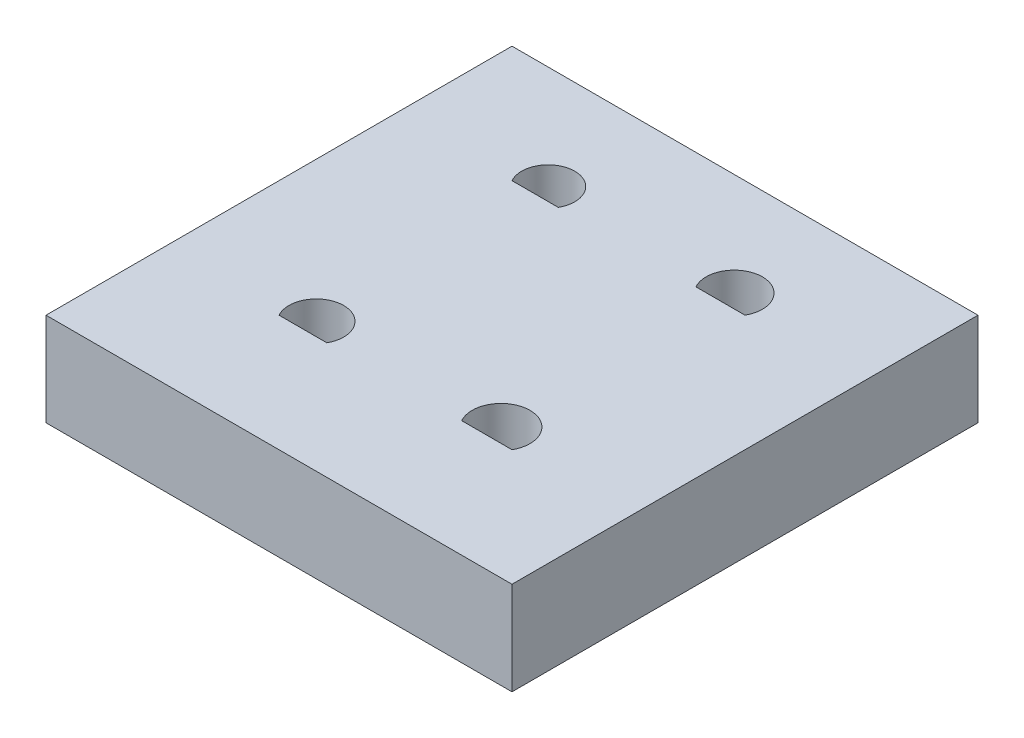
from build123d import *

# Parameters (mm, degrees)
SKETCH2_W           = 25.4
SKETCH2_H           = 25.4
BOSS_EXTRUDE1_DEPTH = 5.08
CUT_EXTRUDE1_DEPTH  = 5.08


with BuildPart() as part:
    # Sketch2 → Boss-Extrude1 (new body)
    with BuildSketch(Plane(origin=(0, 0, 0), x_dir=(1, 0, 0), z_dir=(0, 1, 0))):
        with Locations((12.7, 12.7)):
            Rectangle(SKETCH2_W, SKETCH2_H)
    extrude(amount=BOSS_EXTRUDE1_DEPTH)

    # Sketch3 → Cut-Extrude1 (cut)
    with BuildSketch(Plane(origin=(0, 5.08, 5.08), x_dir=(1, 0, 0), z_dir=(0, 1, 0))):
        with BuildLine():
            Line((6.35, 11.43), (8.957059761, 11.43))
            ThreePointArc((8.957059761, 11.43), (7.653529881, 13.6525), (6.35, 11.43))
        make_face()
        with BuildLine():
            Line((16.307858538, 11.43), (19.05, 11.43))
            ThreePointArc((19.05, 11.43), (17.678929269, 13.7795), (16.307858538, 11.43))
        make_face()
        with BuildLine():
            Line((6.35, 24.13), (8.872157331, 24.13))
            ThreePointArc((8.872157331, 24.13), (7.611078665, 26.289), (6.35, 24.13))
        make_face()
        with BuildLine():
            Line((16.375390855, 24.13), (19.05, 24.13))
            ThreePointArc((19.05, 24.13), (17.712695427, 26.416), (16.375390855, 24.13))
        make_face()
    extrude(amount=-CUT_EXTRUDE1_DEPTH, mode=Mode.SUBTRACT)


solid = part.part
